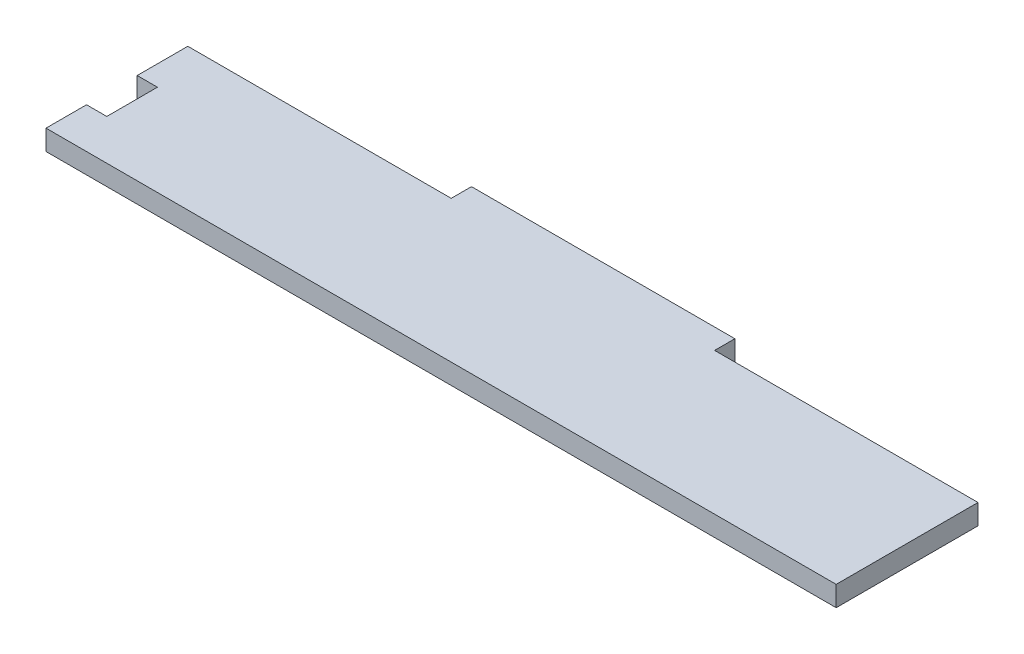
from build123d import *

# Parameters (mm, degrees)
BOSS_EXTRUDE1_DEPTH = 10


with BuildPart() as part:
    # Sketch1 → Boss-Extrude1 (new body)
    with BuildSketch(Plane(origin=(0, 0, 0), x_dir=(1, 0, 0), z_dir=(0, 1, 0))):
        Polygon((0, 70), (-390, 70), (-390, 90), (-380, 90), (-380, 115), (-390, 115), (-390, 140), (-260, 140), (-260, 150), (-130, 150), (-130, 140), (0, 140), align=None)
    extrude(amount=BOSS_EXTRUDE1_DEPTH)


solid = part.part
